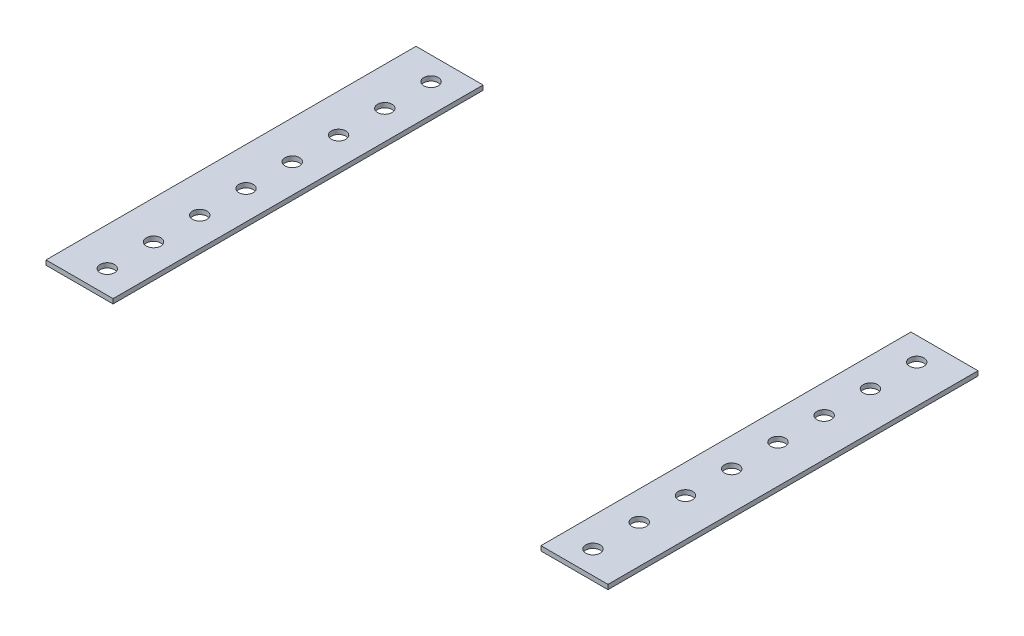
from build123d import *

# Parameters (mm, degrees)
SKETCH1_W             = 36.83
SKETCH1_H             = 203.2
BOSS_EXTRUDE1_DEPTH   = 2.54
BOSS_EXTRUDE1_2_DEPTH = 2.54
SKETCH2_R             = 3.96875
CUT_EXTRUDE1_DEPTH    = 2.54


with BuildPart() as part:
    # Sketch1 → Boss-Extrude1 (new body)
    with BuildSketch(Plane(origin=(0, 0, 0), x_dir=(1, 0, 0), z_dir=(0, 1, 0))):
        with Locations((-119.720108359, 73.899845201)):
            Rectangle(SKETCH1_W, SKETCH1_H)
    extrude(amount=-BOSS_EXTRUDE1_DEPTH)


with BuildPart() as body_2:
    # Sketch1 → Boss-Extrude1 2 (new body)
    with BuildSketch(Plane(origin=(0, 0, 0), x_dir=(1, 0, 0), z_dir=(0, 1, 0))):
        with Locations((152.059891641, 73.899845201)):
            Rectangle(SKETCH1_W, SKETCH1_H)
    extrude(amount=-BOSS_EXTRUDE1_2_DEPTH)


with BuildPart() as cut_extrude1_tool:
    # Sketch2 → Cut-Extrude1 (new body)
    with BuildSketch(Plane(origin=(0, 0, 0), x_dir=(1, 0, 0), z_dir=(0, 1, 0))):
        with Locations((-117.180108359, 162.799845201)):
            Circle(SKETCH2_R)
        with Locations((-117.180108359, 137.399845201)):
            Circle(SKETCH2_R)
        with Locations((-117.180108359, 111.999845201)):
            Circle(SKETCH2_R)
        with Locations((-117.180108359, 86.599845201)):
            Circle(SKETCH2_R)
        with Locations((-117.180108359, 61.199845201)):
            Circle(SKETCH2_R)
        with Locations((-117.180108359, 35.799845201)):
            Circle(SKETCH2_R)
        with Locations((-117.180108359, 10.399845201)):
            Circle(SKETCH2_R)
        with Locations((-117.180108359, -15.000154799)):
            Circle(SKETCH2_R)
        with Locations((149.519891641, -15.000154799)):
            Circle(SKETCH2_R)
        with Locations((149.519891641, 10.399845201)):
            Circle(SKETCH2_R)
        with Locations((149.519891641, 35.799845201)):
            Circle(SKETCH2_R)
        with Locations((149.519891641, 61.199845201)):
            Circle(SKETCH2_R)
        with Locations((149.519891641, 86.599845201)):
            Circle(SKETCH2_R)
        with Locations((149.519891641, 111.999845201)):
            Circle(SKETCH2_R)
        with Locations((149.519891641, 137.399845201)):
            Circle(SKETCH2_R)
        with Locations((149.519891641, 162.799845201)):
            Circle(SKETCH2_R)
    extrude(amount=-CUT_EXTRUDE1_DEPTH)


with BuildPart() as part_1:
    add(part.part)

    # Cut-Extrude1: cut by cut_extrude1_tool
    add(cut_extrude1_tool.part, mode=Mode.SUBTRACT)


with BuildPart() as body_2_1:
    add(body_2.part)

    # Cut-Extrude1: cut by cut_extrude1_tool
    add(cut_extrude1_tool.part, mode=Mode.SUBTRACT)


solid = Compound([part_1.part, body_2_1.part])
